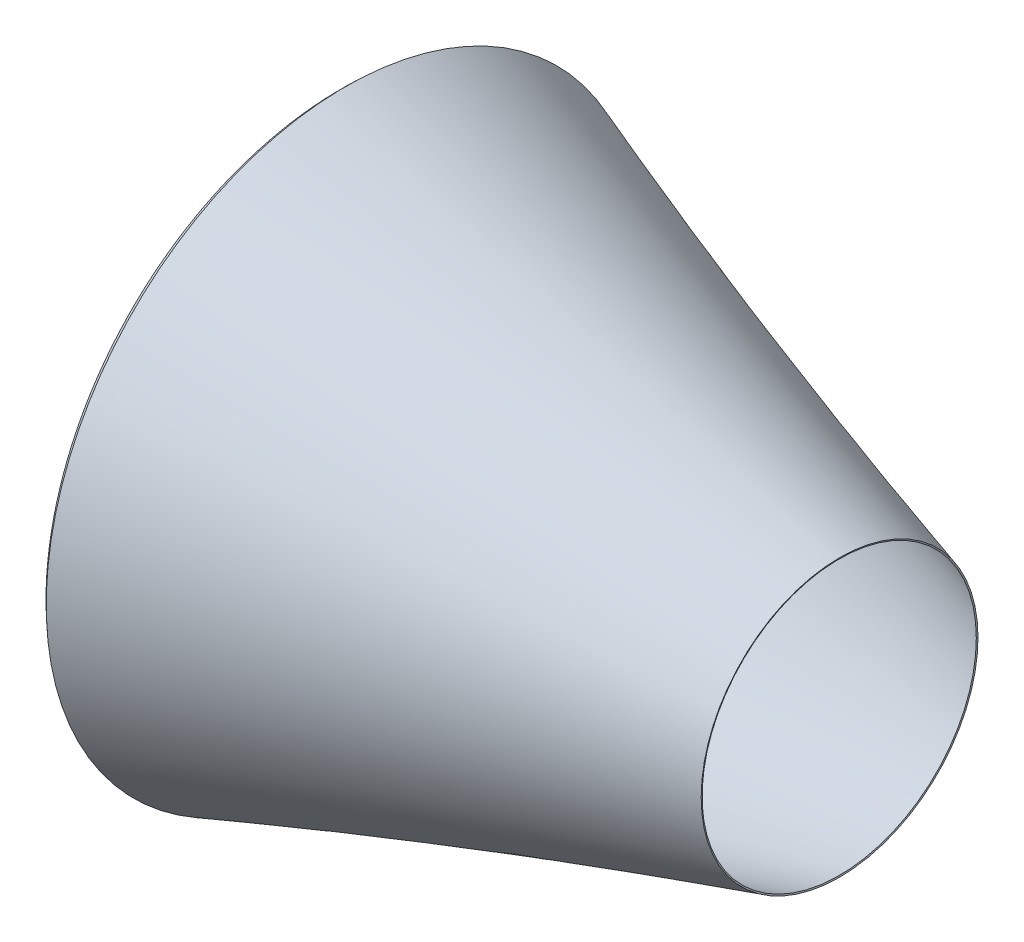
from build123d import *

# Parameters (mm, degrees)
THICKEN1_T1 = 5


with BuildPart() as body_1:
    # Surface-Revolve1: a surface, the sketch's curves turned about an axis
    with BuildLine(Plane.XY, mode=Mode.PRIVATE) as surface_revolve1_1_path:
        Line((113.164522356, 1000), (33.164522356, 1000))
        Line((33.164522356, 1000), (25, 950))
        Line((25, 950), (0, 950))
        add(Edge.make_bspline(
            [(0, 950), (-77.602076819, 1017.819936816), (0, 1085.28552624)],
            knots=[0, 0, 0, 1, 1, 1], degree=2))
        add(Edge.make_bspline(
            [(0, 1085.28552624), (889.916532698, 761.717980416), (1800, 500)],
            knots=[0, 0, 0, 1, 1, 1], degree=2))
    surface_revolve1_1 = Shell.revolve(surface_revolve1_1_path.wire(), 360, Axis((0, 0, 0), (1, 0, 0)))
    add(Solid.thicken(surface_revolve1_1, THICKEN1_T1))


solid = body_1.part
